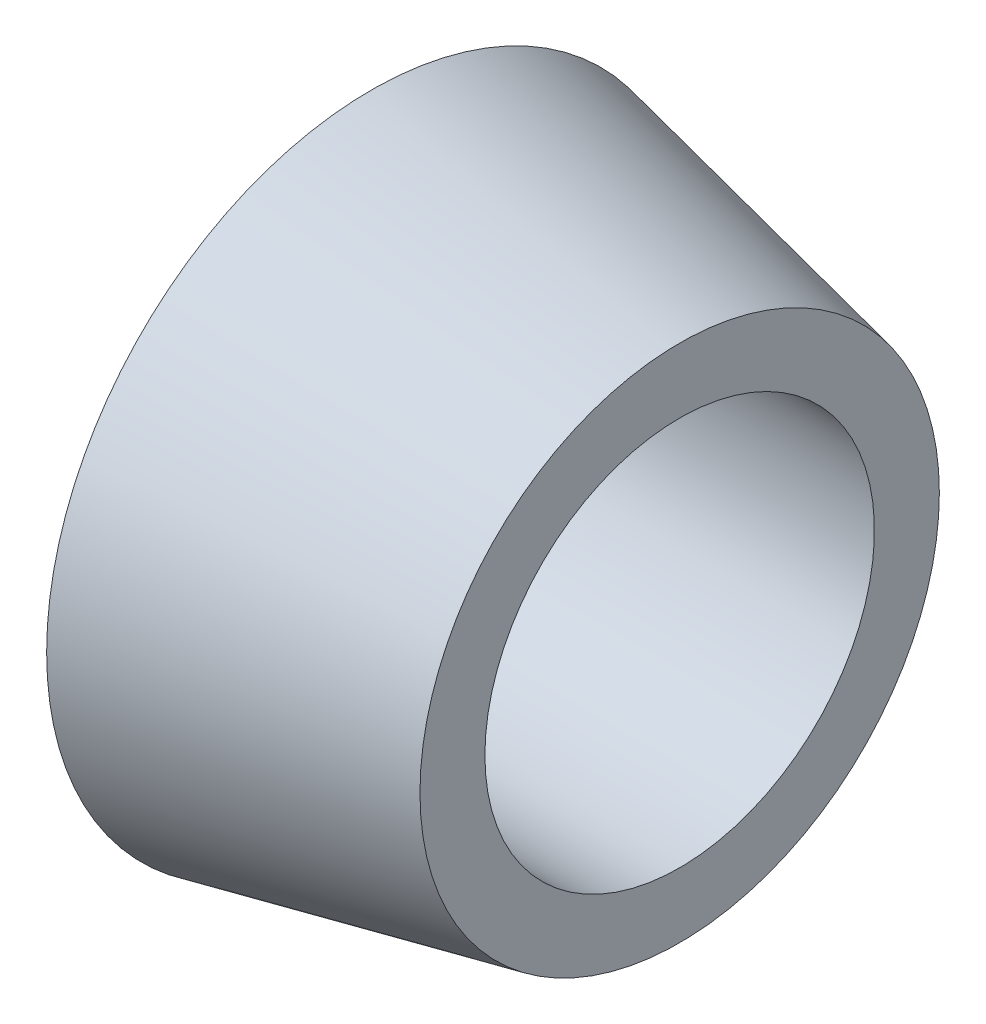
from build123d import *


with BuildPart() as part:
    # Szkic1 → Obrót1 (revolve)
    with BuildSketch(Plane.XY):
        Polygon((0, 6), (0, 10), (9.5, 8), (9.5, 6), align=None)
    revolve(axis=Axis((0, 0, 0), (1, 0, 0)))


solid = part.part
